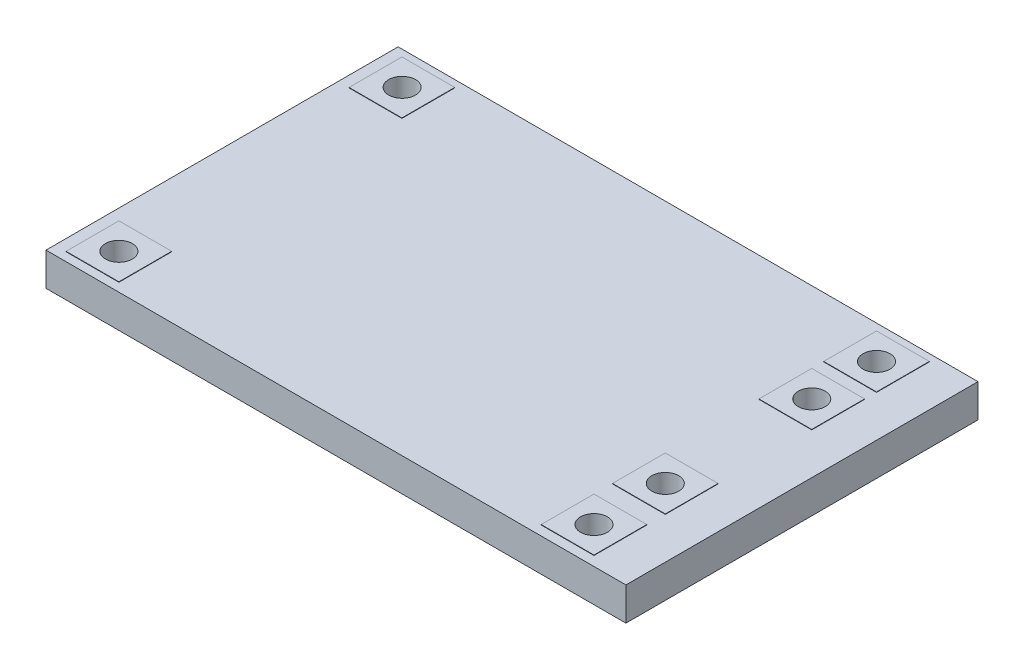
from build123d import *

# Parameters (mm, degrees)
SKETCH1_W           = 28
SKETCH1_H           = 17
SKETCH1_W_2         = 2.55
SKETCH1_H_2         = 2.55
BOSS_EXTRUDE2_DEPTH = 1.6
SKETCH1_4_W         = 2.55
SKETCH1_4_H         = 2.55
SKETCH1_4_R         = 0.65
BOSS_EXTRUDE3_DEPTH = 1.62


with BuildPart() as part:
    # Sketch1 → Boss-Extrude2 (new body)
    with BuildSketch(Plane(origin=(0, 0, 0), x_dir=(1, 0, 0), z_dir=(0, 1, 0))):
        with Locations((126.930429576, 228.501666699)):
            Rectangle(SKETCH1_W, SKETCH1_H)
        with Locations((114.760575643, 221.691567702)):
            Rectangle(SKETCH1_W_2, SKETCH1_H_2, mode=Mode.SUBTRACT)
        with Locations((137.654571072, 221.735710918)):
            Rectangle(SKETCH1_W_2, SKETCH1_H_2, mode=Mode.SUBTRACT)
        with Locations((137.658202973, 225.175578697)):
            Rectangle(SKETCH1_W_2, SKETCH1_H_2, mode=Mode.SUBTRACT)
        with Locations((114.740971772, 235.375518488)):
            Rectangle(SKETCH1_W_2, SKETCH1_H_2, mode=Mode.SUBTRACT)
        with Locations((137.659563776, 232.245059936)):
            Rectangle(SKETCH1_W_2, SKETCH1_H_2, mode=Mode.SUBTRACT)
        with Locations((137.655429576, 235.376666699)):
            Rectangle(SKETCH1_W_2, SKETCH1_H_2, mode=Mode.SUBTRACT)
    extrude(amount=BOSS_EXTRUDE2_DEPTH)

    # Sketch1_4 → Boss-Extrude3 (add)
    # profile 1 of 6: a face of its own
    with BuildSketch(Plane(origin=(0, 0, 0), x_dir=(1, 0, 0), z_dir=(0, 1, 0))):
        with Locations((137.655429576, 235.376666699)):
            Rectangle(SKETCH1_4_W, SKETCH1_4_H)
        with Locations((137.655429576, 235.376666699)):
            Circle(SKETCH1_4_R, mode=Mode.SUBTRACT)
    # profile 2 of 6: a face of its own
    with BuildSketch(Plane(origin=(0, 0, 0), x_dir=(1, 0, 0), z_dir=(0, 1, 0))):
        with Locations((114.740971772, 235.375518488)):
            Rectangle(SKETCH1_4_W, SKETCH1_4_H)
        with Locations((114.740971772, 235.384673509)):
            Circle(SKETCH1_4_R, mode=Mode.SUBTRACT)
    # profile 3 of 6: a face of its own
    with BuildSketch(Plane(origin=(0, 0, 0), x_dir=(1, 0, 0), z_dir=(0, 1, 0))):
        with Locations((137.659563776, 232.245059936)):
            Rectangle(SKETCH1_4_W, SKETCH1_4_H)
        with Locations((137.659563776, 232.245059936)):
            Circle(SKETCH1_4_R, mode=Mode.SUBTRACT)
    # profile 4 of 6: a face of its own
    with BuildSketch(Plane(origin=(0, 0, 0), x_dir=(1, 0, 0), z_dir=(0, 1, 0))):
        with Locations((137.658202973, 225.175578697)):
            Rectangle(SKETCH1_4_W, SKETCH1_4_H)
        with Locations((137.658202973, 225.175578697)):
            Circle(SKETCH1_4_R, mode=Mode.SUBTRACT)
    # profile 5 of 6: a face of its own
    with BuildSketch(Plane(origin=(0, 0, 0), x_dir=(1, 0, 0), z_dir=(0, 1, 0))):
        with Locations((137.654571072, 221.735710918)):
            Rectangle(SKETCH1_4_W, SKETCH1_4_H)
        with Locations((137.654571072, 221.735710918)):
            Circle(SKETCH1_4_R, mode=Mode.SUBTRACT)
    # profile 6 of 6: a face of its own
    with BuildSketch(Plane(origin=(0, 0, 0), x_dir=(1, 0, 0), z_dir=(0, 1, 0))):
        with Locations((114.760575643, 221.691567702)):
            Rectangle(SKETCH1_4_W, SKETCH1_4_H)
        with Locations((114.760575643, 221.691567702)):
            Circle(SKETCH1_4_R, mode=Mode.SUBTRACT)
    extrude(amount=BOSS_EXTRUDE3_DEPTH)


solid = part.part
